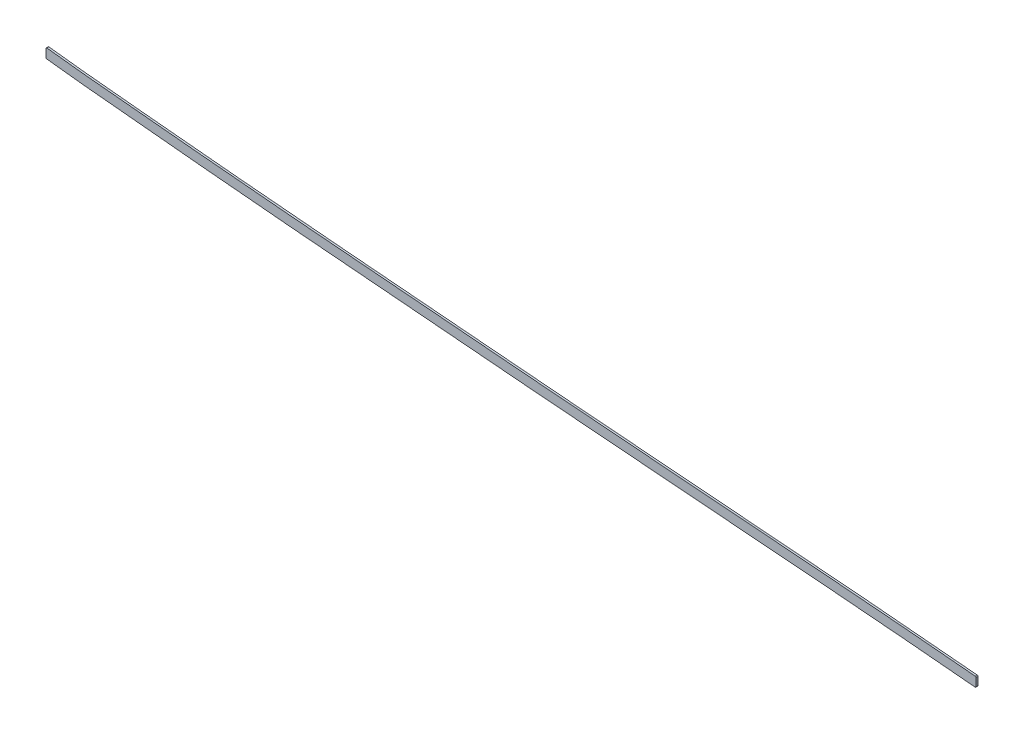
from build123d import *

# Parameters (mm, degrees)
BOSS_EXTRUDE1_DEPTH = 1.5875
FILLET1_R           = 1.27


with BuildPart() as part:
    # Sketch2 → Boss-Extrude1 (new body, symmetric)
    with BuildSketch(Plane.XY):
        with BuildLine():
            add(Edge.make_bspline(
                [(825.5, 263.72872798), (833.004293944, 262.763036085), (840.535916247, 261.846014478), (848.126574562, 260.964164828), (892.90639318, 255.945629274), (937.686211733, 251.779150949), (973.452075064, 248.227669425), (1071.946672141, 239.051054038), (1170.441269319, 229.731506738), (1231.791940344, 224.503945813), (1324.899336146, 216.790627817), (1418.006730935, 209.040117978), (1449.742935921, 206.361809936), (1636.928606778, 190.521130342), (1824.114277635, 175.409157235), (1979.966947376, 164.299650253), (2139.396932204, 151.743219852), (2298.826916202, 137.00172879), (2303.011455291, 136.613290392), (2307.202438398, 136.22270903), (2311.4, 135.829939705)],
                knots=[78.681340958, 78.681340958, 78.681340958, 78.681340958, 78.681340958, 78.681340958, 82.46579272, 82.46579272, 82.46579272, 100.7932901, 100.7932901, 100.7932901, 131.0989539, 131.0989539, 131.0989539, 146.7691983, 146.7691983, 146.7691983, 223.5339586, 223.5339586, 223.5339586, 225.60075304, 225.60075304, 225.60075304, 225.60075304, 225.60075304, 225.60075304], degree=5))
            Line((825.5, 263.72872798), (825.5, 248.364439806))
            add(Edge.make_bspline(
                [(825.5, 248.364439806), (827.20768691, 248.14708351), (833.784664511, 247.321927102), (845.28106727, 245.953419483), (860.086531547, 244.295598067), (879.830703434, 242.186646028), (904.369967092, 239.698279806), (933.571022669, 236.832150625), (962.642718041, 234.023667741), (991.762593943, 231.241975908), (1021.072010315, 228.475862291), (1060.376437315, 224.796956681), (1109.513015577, 220.184378862), (1168.511190361, 214.817071985), (1227.500129793, 209.662054042), (1306.133167947, 203.021178328), (1404.361477105, 194.920725932), (1522.239851071, 184.918066624), (1640.182856491, 175.167007786), (1758.165352567, 165.757639485), (1876.155384769, 156.590937079), (1994.08749188, 147.453250142), (2092.268692061, 139.624216053), (2170.748029042, 133.079656729), (2219.771730977, 128.842227836), (2258.983988247, 125.347211495), (2286.236620906, 122.865952448), (2303.710498295, 121.243617864), (2311.4, 120.523308441)],
                knots=[78.875303138, 78.875303138, 78.875303138, 78.875303138, 79.386176103, 80.841530691, 82.29688528, 83.752239868, 86.662949044, 89.57365822, 92.484367397, 95.395076573, 98.305785749, 101.216494926, 107.037913278, 112.859331631, 118.680749984, 124.502168336, 136.145005042, 147.787841747, 159.430678452, 171.073515158, 182.716351863, 194.359188568, 206.002025273, 211.823443626, 217.644861979, 220.555571155, 223.466280331, 225.740445061, 225.740445061, 225.740445061, 225.740445061], degree=3))
            Line((2311.4, 120.523308441), (2311.4, 135.829939705))
        make_face()
    extrude(amount=BOSS_EXTRUDE1_DEPTH, both=True)

    # Fillet1
    fillet1_edges = [part.edges().sort_by_distance(p)[0] for p in [
        (2311.4, 120.523308441, -0.79375),
        (2311.4, 135.829939705, -0.79375),
        (825.5, 248.364439806, -0.79375),
        (825.5, 263.72872798, 0.79375),
    ]]
    fillet(fillet1_edges, radius=FILLET1_R)


solid = part.part
